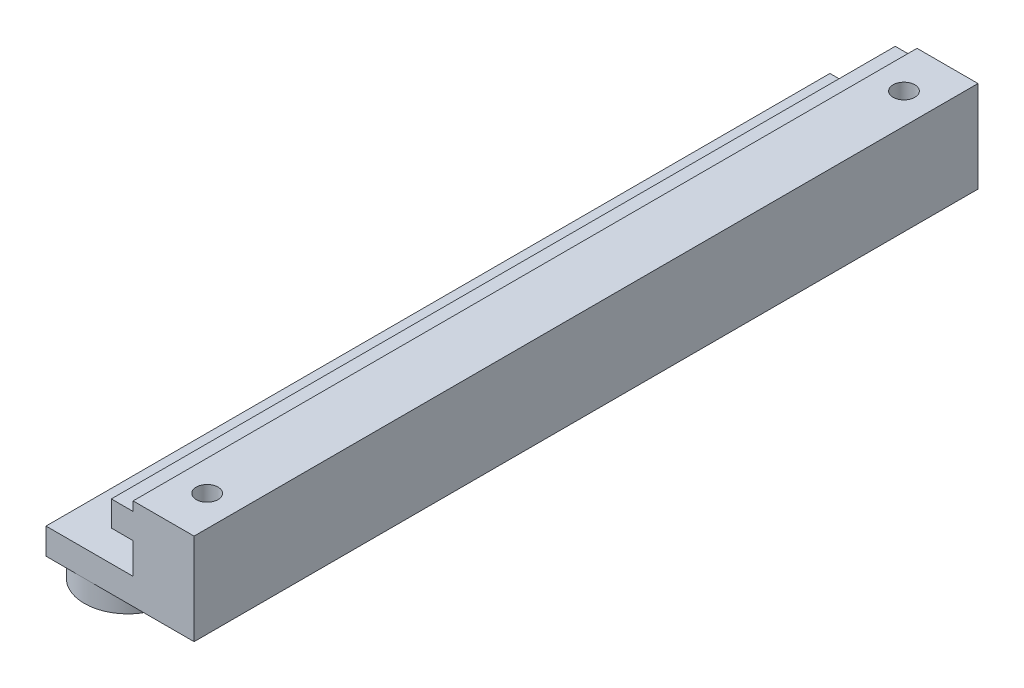
from build123d import *

# Parameters (mm, degrees)
MAIN_DEPTH         = 90
SKETCH2_R          = 5
PLOT_DEPTH         = 2.5
SKETCH3_R          = 1.25
HOLEFIX_DEPTH      = 14
SKETCH4_R          = 1.25
CUT_EXTRUDE4_DEPTH = 14
SKETCH5_W          = 31.518406853
SKETCH5_H          = 19.182170192
CUT_EXTRUDE5_DEPTH = 91


with BuildPart() as part:
    # Sketch1 → Main (new body)
    with BuildSketch(Plane.XY):
        Polygon((-10, 7.5), (0, 7.5), (0, 3.95), (-2.5, 3.95), (-2.5, 1.05), (0, 1.05), (0, 0), (7, 0), (7, 10.5), (-10, 10.5), align=None)
    extrude(amount=MAIN_DEPTH)

    # Sketch2 → Plot (add)
    with BuildSketch(Plane(origin=(0, 10.5, 0), x_dir=(1, 0, 0), z_dir=(0, 1, 0))):
        with Locations((-5.6, -85)):
            Circle(SKETCH2_R)
        with Locations((-5.6, -10.2)):
            Circle(SKETCH2_R)
    extrude(amount=PLOT_DEPTH)

    # Sketch3 → HoleFix (cut, through all)
    with BuildSketch(Plane(origin=(0, 13, 0), x_dir=(1, 0, 0), z_dir=(0, 1, 0))):
        with Locations((-5.6, -10.2)):
            Circle(SKETCH3_R)
        with Locations((-5.6, -85)):
            Circle(SKETCH3_R)
    extrude(amount=-HOLEFIX_DEPTH, mode=Mode.SUBTRACT)

    # Sketch4 → Cut-Extrude4 (cut, through all)
    with BuildSketch(Plane(origin=(7, 0, 0), x_dir=(0, 0, -1), z_dir=(0, 1, 0))):
        with Locations((-85, 3.5)):
            Circle(SKETCH4_R)
        with Locations((-5, 3.5)):
            Circle(SKETCH4_R)
    extrude(amount=CUT_EXTRUDE4_DEPTH, mode=Mode.SUBTRACT)


with BuildPart() as body_2:
    # Mirror2: mirrored copy
    add(part.part.mirror(Plane.ZX.offset(18.5)))


with BuildPart() as part_1:
    add(part.part)

    # Sketch5 → Cut-Extrude5 (cut, through all)
    with BuildSketch(Plane.XY.offset(90)):
        with Locations((-2.991193443, 6.5365617)):
            Rectangle(SKETCH5_W, SKETCH5_H)
    extrude(amount=-CUT_EXTRUDE5_DEPTH, mode=Mode.SUBTRACT)


solid = body_2.part
